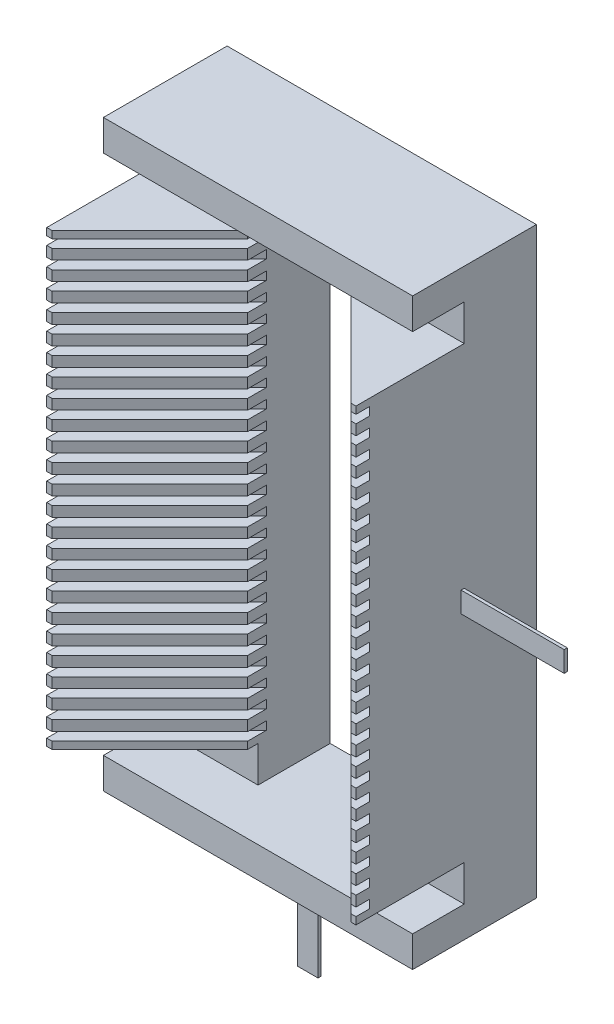
from build123d import *

# Parameters (mm, degrees)
BOSS_EXTRUDE1_DEPTH     = 1.1
BOSS_EXTRUDE1_2_DEPTH   = 1.1
CUT_EXTRUDE2_DEPTH      = 0.4
LPATTERN1_COUNT         = 24
LPATTERN1_PITCH         = 1.8
LPATTERN1_2_COUNT       = 24
LPATTERN1_2_PITCH       = 1.8
BOSS_EXTRUDE3_DEPTH     = 15
SKETCH9_W               = 10
SKETCH9_H               = 2
SKETCH9_W_2             = 2
SKETCH9_H_2             = 10
BOSS_EXTRUDE4_DEPTH     = 0.3
SKETCH12_W              = 10
SKETCH12_H              = 3.5
CUT_EXTRUDE3_DEPTH      = 11.5
CUT_EXTRUDE3_DEPTH_BACK = 8


with BuildPart() as part:
    # Sketch1 → Boss-Extrude1 (new body, symmetric)
    with BuildSketch(Plane(origin=(0, 0, 0), x_dir=(1, 0, 0), z_dir=(0, 1, 0))):
        Polygon((5, -8), (14.5, -17.5), (15, -17.5), (15, 0), (5, 0), align=None)
    boss_extrude1 = extrude(amount=BOSS_EXTRUDE1_DEPTH, both=True)


with BuildPart() as body_2:
    # Sketch1 → Boss-Extrude1 2 (new body, symmetric)
    with BuildSketch(Plane(origin=(0, 0, 0), x_dir=(1, 0, 0), z_dir=(0, 1, 0))):
        Polygon((-15, -17.5), (-15, 0), (-5, 0), (-5, -8), (-14.5, -17.5), align=None)
    boss_extrude1_2 = extrude(amount=BOSS_EXTRUDE1_2_DEPTH, both=True)


with BuildPart() as cut_extrude2_tool:
    # Sketch2 → Cut-Extrude2 (new body, symmetric)
    with BuildSketch(Plane(origin=(0, 0, 0), x_dir=(1, 0, 0), z_dir=(0, 1, 0))):
        Polygon((-5, -8), (-5, -6.2), (-15, -16.2), (-15, -17.5), (-14.5, -17.5), align=None)
        Polygon((15, -17.5), (15, -16.2), (5, -6.2), (5, -8), (14.5, -17.5), align=None)
    cut_extrude2 = extrude(amount=CUT_EXTRUDE2_DEPTH, both=True)


with BuildPart() as part_1:
    add(part.part)

    # Cut-Extrude2: cut by cut_extrude2_tool
    add(cut_extrude2_tool.part, mode=Mode.SUBTRACT)



with BuildPart() as body_2_1:
    add(body_2.part)

    # Cut-Extrude2: cut by cut_extrude2_tool
    add(cut_extrude2_tool.part, mode=Mode.SUBTRACT)


with BuildPart() as part_2:
    add(part_1.part)

    add(body_2_1.part)  # LPattern1 merges body 2
    # LPattern1: Boss-Extrude1, Boss-Extrude1 2 ×24
    with Locations(*[(0, i * LPATTERN1_PITCH, 0) for i in range(1, LPATTERN1_COUNT)]):
        add(boss_extrude1)
        add(boss_extrude1_2)

    # LPattern1 2: Cut-Extrude2 ×24
    with Locations(*[(0, i * LPATTERN1_2_PITCH, 0) for i in range(1, LPATTERN1_2_COUNT)]):
        add(cut_extrude2, mode=Mode.SUBTRACT)

    # Sketch4 → Boss-Extrude3 (add, symmetric)
    with BuildSketch(Plane(origin=(0, 0, 0), x_dir=(0, 0, -1), z_dir=(1, 0, 0))):
        Polygon((0, -1.1), (0, -7.6), (-12, -7.6), (-12, -4.6), (-7, -4.6), (-7, -1.1), align=None)
        Polygon((-7, 42.5), (0, 42.5), (0, 49), (-12, 49), (-12, 46), (-7, 46), align=None)
    extrude(amount=BOSS_EXTRUDE3_DEPTH, both=True)

    # Sketch9 → Boss-Extrude4 (add)
    with BuildSketch(Plane(origin=(0, 0, 7), x_dir=(-1, 0, 0), z_dir=(0, 0, -1))):
        with Locations((-20, 20.934874709)):
            Rectangle(SKETCH9_W, SKETCH9_H)
        with Locations((-0.113633894, -12.6)):
            Rectangle(SKETCH9_W_2, SKETCH9_H_2)
    extrude(amount=-BOSS_EXTRUDE4_DEPTH)

    # Sketch12 → Cut-Extrude3 (cut, two sides)
    with BuildSketch(Plane.XY.offset(7)) as cut_extrude3_sk:
        with Locations((0, -2.85)):
            Rectangle(SKETCH12_W, SKETCH12_H)
        with Locations((0, 44.25)):
            Rectangle(SKETCH12_W, SKETCH12_H)
    extrude(amount=CUT_EXTRUDE3_DEPTH, mode=Mode.SUBTRACT)
    extrude(cut_extrude3_sk.sketch, amount=-CUT_EXTRUDE3_DEPTH_BACK, mode=Mode.SUBTRACT)


solid = part_2.part
